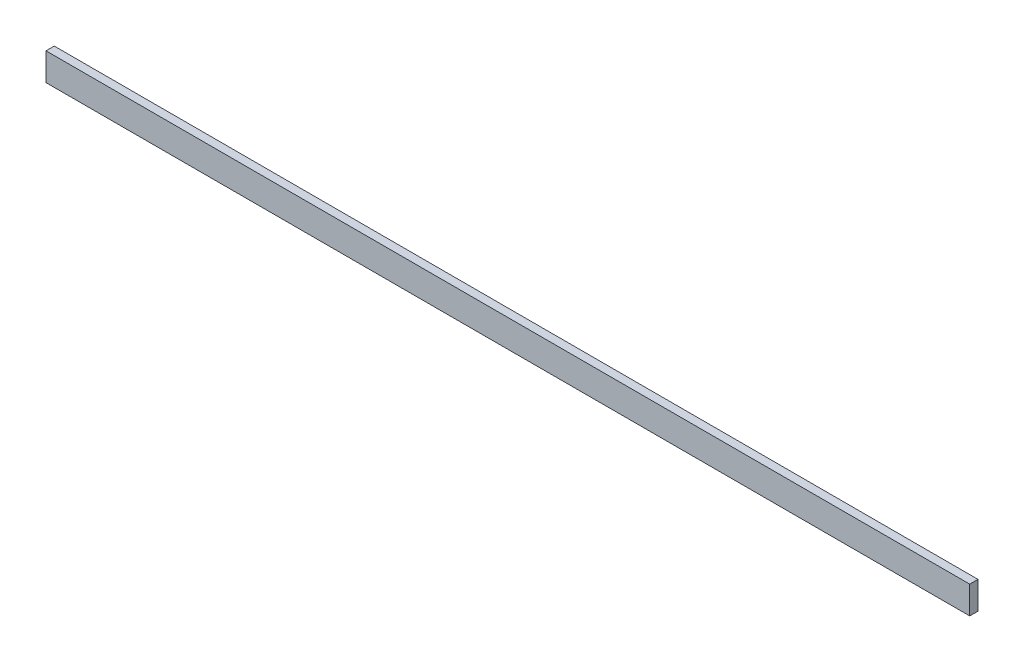
from build123d import *

# Parameters (mm, degrees)
SKETCH1_W           = 335
SKETCH1_H           = 10
BOSS_EXTRUDE1_DEPTH = 3


with BuildPart() as part:
    # Sketch1 → Boss-Extrude1 (new body)
    with BuildSketch(Plane.XY):
        with Locations((167.5, -5)):
            Rectangle(SKETCH1_W, SKETCH1_H)
    extrude(amount=BOSS_EXTRUDE1_DEPTH)


solid = part.part
